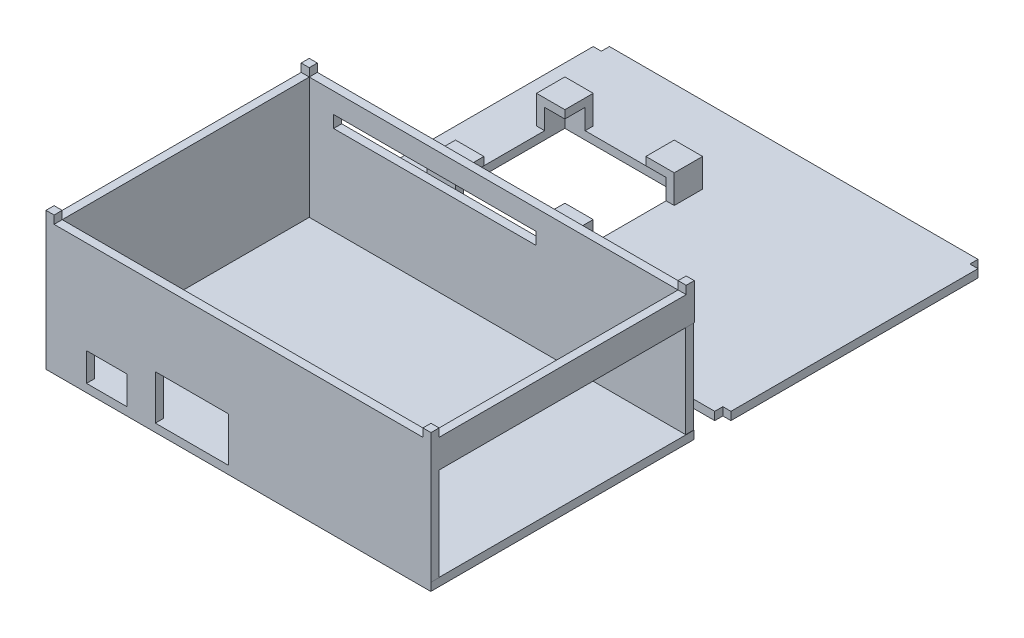
from build123d import *

# Parameters (mm, degrees)
ESQUISSE1_W                = 95
ESQUISSE1_H                = 65
BOSS_EXTRU_1_DEPTH         = 2
ESQUISSE22_W               = 65
ESQUISSE22_H               = 30
BOSS_EXTRU_6_DEPTH         = 2
ESQUISSE23_W               = 93.058073386
ESQUISSE23_H               = 30
BOSS_EXTRU_7_DEPTH         = 2
ESQUISSE26_W               = 92.923280672
ESQUISSE26_H               = 30
BOSS_EXTRU_8_DEPTH         = 2
ESQUISSE27_W               = 10
ESQUISSE27_H               = 7
ENL_V_MAT_EXTRU_4_DEPTH    = 2
ESQUISSE28_W               = 18
ESQUISSE28_H               = 11
ENL_V_MAT_EXTRU_5_DEPTH    = 2
ESQUISSE30_W               = 65
ESQUISSE30_H               = 7
BOSS_EXTRU_9_DEPTH         = 2
ESQUISSE31_W               = 95
ESQUISSE31_H               = 65
BOSS_EXTRU_11_DEPTH        = 2
ESQUISSE32_W               = 2
ESQUISSE32_H               = 2
BOSS_EXTRU_12_DEPTH        = 2
R_P_TITION_LIN_AIRE1_COUNT = 2
R_P_TITION_LIN_AIRE1_PITCH = 63
ESQUISSE33_W               = 2
ESQUISSE33_H               = 2
BOSS_EXTRU_13_DEPTH        = 2
R_P_TITION_LIN_AIRE4_COUNT = 2
R_P_TITION_LIN_AIRE4_PITCH = 63
ESQUISSE34_W               = 2
ESQUISSE34_H               = 2
ENL_V_MAT_EXTRU_6_DEPTH    = 2
R_P_TITION_LIN_AIRE5_COUNT = 2
R_P_TITION_LIN_AIRE5_PITCH = 63
ESQUISSE35_W               = 2
ESQUISSE35_H               = 2
ENL_V_MAT_EXTRU_7_DEPTH    = 2
R_P_TITION_LIN_AIRE7_COUNT = 2
R_P_TITION_LIN_AIRE7_PITCH = 63
ESQUISSE36_W               = 30
ESQUISSE36_H               = 30
ENL_V_MAT_EXTRU_8_DEPTH    = 2
ESQUISSE37_W               = 5
ESQUISSE37_H               = 7
BOSS_EXTRU_14_DEPTH        = 2
ESQUISSE38_W               = 7
ESQUISSE38_H               = 7
BOSS_EXTRU_15_DEPTH        = 2
ESQUISSE39_W               = 5
ESQUISSE39_H               = 5
BOSS_EXTRU_16_DEPTH        = 2
ESQUISSE40_W               = 5
ESQUISSE40_H               = 7
BOSS_EXTRU_17_DEPTH        = 2
ESQUISSE41_W               = 7
ESQUISSE41_H               = 7
BOSS_EXTRU_19_DEPTH        = 2
ESQUISSE43_W               = 5.015402863
ESQUISSE43_H               = 5
BOSS_EXTRU_20_DEPTH        = 2
ESQUISSE44_W               = 5
ESQUISSE44_H               = 7
BOSS_EXTRU_21_DEPTH        = 2
ESQUISSE45_W               = 7
ESQUISSE45_H               = 7
BOSS_EXTRU_22_DEPTH        = 2
ESQUISSE46_W               = 5.00193494
ESQUISSE46_H               = 5
BOSS_EXTRU_23_DEPTH        = 2
ESQUISSE48_W               = 5
ESQUISSE48_H               = 7
BOSS_EXTRU_24_DEPTH        = 2
ESQUISSE49_W               = 7
ESQUISSE49_H               = 7
BOSS_EXTRU_25_DEPTH        = 2
ESQUISSE50_W               = 5
ESQUISSE50_H               = 5
BOSS_EXTRU_26_DEPTH        = 2
ESQUISSE51_W               = 50
ESQUISSE51_H               = 3
ENL_V_MAT_EXTRU_9_DEPTH    = 2


with BuildPart() as part:
    # Esquisse1 → Boss.-Extru.1 (new body)
    with BuildSketch(Plane(origin=(0, 0, 0), x_dir=(1, 0, 0), z_dir=(0, 1, 0))):
        with Locations((-31.555880748, 23.267126069)):
            Rectangle(ESQUISSE1_W, ESQUISSE1_H)
    extrude(amount=BOSS_EXTRU_1_DEPTH)

    # Esquisse22 → Boss.-Extru.6 (add)
    with BuildSketch(Plane.ZY.offset(79.055880748)):
        with Locations((-23.267126069, 17)):
            Rectangle(ESQUISSE22_W, ESQUISSE22_H)
    extrude(amount=-BOSS_EXTRU_6_DEPTH)

    # Esquisse23 → Boss.-Extru.7 (add)
    with BuildSketch(Plane.XY.offset(9.232873931)):
        with Locations((-30.526844055, 17)):
            Rectangle(ESQUISSE23_W, ESQUISSE23_H)
    extrude(amount=-BOSS_EXTRU_7_DEPTH)

    # Esquisse26 → Boss.-Extru.8 (add)
    with BuildSketch(Plane(origin=(0, 0, -55.767126069), x_dir=(-1, 0, 0), z_dir=(0, 0, -1))):
        with Locations((30.594240412, 17)):
            Rectangle(ESQUISSE26_W, ESQUISSE26_H)
    extrude(amount=-BOSS_EXTRU_8_DEPTH)

    # Esquisse27 → Enlèv. mat.-Extru.4 (cut)
    with BuildSketch(Plane.XY.offset(9.232873931)):
        with Locations((-64.055880748, 5.5)):
            Rectangle(ESQUISSE27_W, ESQUISSE27_H)
    extrude(amount=-ENL_V_MAT_EXTRU_4_DEPTH, mode=Mode.SUBTRACT)

    # Esquisse28 → Enlèv. mat.-Extru.5 (cut)
    with BuildSketch(Plane.XY.offset(9.232873931)):
        with Locations((-43.055880748, 7.5)):
            Rectangle(ESQUISSE28_W, ESQUISSE28_H)
    extrude(amount=-ENL_V_MAT_EXTRU_5_DEPTH, mode=Mode.SUBTRACT)

    # Esquisse30 → Boss.-Extru.9 (add)
    with BuildSketch(Plane(origin=(16.002192638, 0, 0), x_dir=(0, 0, -1), z_dir=(1, 0, 0))):
        with Locations((23.267126069, 28.5)):
            Rectangle(ESQUISSE30_W, ESQUISSE30_H)
    extrude(amount=-BOSS_EXTRU_9_DEPTH)

    # Esquisse32 → Boss.-Extru.12 (add)
    with BuildSketch(Plane(origin=(0, 32, 0), x_dir=(1, 0, 0), z_dir=(0, 1, 0))):
        with Locations((-78.055880748, 54.767126069)):
            Rectangle(ESQUISSE32_W, ESQUISSE32_H)
    boss_extru_12 = extrude(amount=BOSS_EXTRU_12_DEPTH)

    # Répétition linéaire1: Boss.-Extru.12 ×2
    with Locations(*[(0, 0, i * R_P_TITION_LIN_AIRE1_PITCH) for i in range(1, R_P_TITION_LIN_AIRE1_COUNT)]):
        add(boss_extru_12)

    # Esquisse33 → Boss.-Extru.13 (add)
    with BuildSketch(Plane(origin=(0, 32, 0), x_dir=(1, 0, 0), z_dir=(0, 1, 0))):
        with Locations((15.002192638, 54.767126069)):
            Rectangle(ESQUISSE33_W, ESQUISSE33_H)
    boss_extru_13 = extrude(amount=BOSS_EXTRU_13_DEPTH)

    # Répétition linéaire4: Boss.-Extru.13 ×2
    with Locations(*[(0, 0, i * R_P_TITION_LIN_AIRE4_PITCH) for i in range(1, R_P_TITION_LIN_AIRE4_COUNT)]):
        add(boss_extru_13)

    # Esquisse51 → Enlèv. mat.-Extru.9 (cut)
    with BuildSketch(Plane(origin=(0, 0, -55.767126069), x_dir=(-1, 0, 0), z_dir=(0, 0, -1))):
        with Locations((46.055880748, 25.5)):
            Rectangle(ESQUISSE51_W, ESQUISSE51_H)
    extrude(amount=-ENL_V_MAT_EXTRU_9_DEPTH, mode=Mode.SUBTRACT)


with BuildPart() as body_2:
    # Esquisse31 → Boss.-Extru.11 (new body)
    with BuildSketch(Plane(origin=(0, 0, 0), x_dir=(1, 0, 0), z_dir=(0, 1, 0))):
        with Locations((-31.027576349, 94.847888589)):
            Rectangle(ESQUISSE31_W, ESQUISSE31_H)
    extrude(amount=BOSS_EXTRU_11_DEPTH)

    # Esquisse34 → Enlèv. mat.-Extru.6 (cut)
    with BuildSketch(Plane(origin=(0, 2, 0), x_dir=(1, 0, 0), z_dir=(0, 1, 0))):
        with Locations((-77.527576349, 126.347888589)):
            Rectangle(ESQUISSE34_W, ESQUISSE34_H)
    enl_v_mat_extru_6 = extrude(amount=-ENL_V_MAT_EXTRU_6_DEPTH, mode=Mode.SUBTRACT)

    # Répétition linéaire5: Enlèv. mat.-Extru.6 ×2
    with Locations(*[(0, 0, i * R_P_TITION_LIN_AIRE5_PITCH) for i in range(1, R_P_TITION_LIN_AIRE5_COUNT)]):
        add(enl_v_mat_extru_6, mode=Mode.SUBTRACT)

    # Esquisse35 → Enlèv. mat.-Extru.7 (cut)
    with BuildSketch(Plane(origin=(0, 2, 0), x_dir=(1, 0, 0), z_dir=(0, 1, 0))):
        with Locations((15.472423651, 126.347888589)):
            Rectangle(ESQUISSE35_W, ESQUISSE35_H)
    enl_v_mat_extru_7 = extrude(amount=-ENL_V_MAT_EXTRU_7_DEPTH, mode=Mode.SUBTRACT)

    # Répétition linéaire7: Enlèv. mat.-Extru.7 ×2
    with Locations(*[(0, 0, i * R_P_TITION_LIN_AIRE7_PITCH) for i in range(1, R_P_TITION_LIN_AIRE7_COUNT)]):
        add(enl_v_mat_extru_7, mode=Mode.SUBTRACT)

    # Esquisse36 → Enlèv. mat.-Extru.8 (cut)
    with BuildSketch(Plane(origin=(0, 2, 0), x_dir=(1, 0, 0), z_dir=(0, 1, 0))):
        with Locations((-51.527576349, 91.347888589)):
            Rectangle(ESQUISSE36_W, ESQUISSE36_H)
    extrude(amount=-ENL_V_MAT_EXTRU_8_DEPTH, mode=Mode.SUBTRACT)

    # Esquisse37 → Boss.-Extru.14 (add)
    with BuildSketch(Plane(origin=(-66.527576349, 0, 0), x_dir=(0, 0, -1), z_dir=(1, 0, 0))):
        with Locations((103.847888589, 5.5)):
            Rectangle(ESQUISSE37_W, ESQUISSE37_H)
    extrude(amount=-BOSS_EXTRU_14_DEPTH)

    # Esquisse38 → Boss.-Extru.15 (add)
    with BuildSketch(Plane(origin=(0, 0, -106.347888589), x_dir=(-1, 0, 0), z_dir=(0, 0, -1))):
        with Locations((65.027576349, 5.5)):
            Rectangle(ESQUISSE38_W, ESQUISSE38_H)
    extrude(amount=BOSS_EXTRU_15_DEPTH)

    # Esquisse39 → Boss.-Extru.16 (add)
    with BuildSketch(Plane(origin=(0, 9, 0), x_dir=(1, 0, 0), z_dir=(0, 1, 0))):
        with Locations((-64.027576349, 103.847888589)):
            Rectangle(ESQUISSE39_W, ESQUISSE39_H)
    extrude(amount=-BOSS_EXTRU_16_DEPTH)

    # Esquisse40 → Boss.-Extru.17 (add)
    with BuildSketch(Plane(origin=(-66.527576349, 0, 0), x_dir=(0, 0, -1), z_dir=(1, 0, 0))):
        with Locations((78.847888589, 5.5)):
            Rectangle(ESQUISSE40_W, ESQUISSE40_H)
    extrude(amount=-BOSS_EXTRU_17_DEPTH)

    # Esquisse41 → Boss.-Extru.19 (add)
    with BuildSketch(Plane.XY.offset(-76.347888589)):
        with Locations((-65.027576349, 5.5)):
            Rectangle(ESQUISSE41_W, ESQUISSE41_H)
    extrude(amount=BOSS_EXTRU_19_DEPTH)

    # Esquisse43 → Boss.-Extru.20 (add)
    with BuildSketch(Plane(origin=(0, 9, 0), x_dir=(1, 0, 0), z_dir=(0, 1, 0))):
        with Locations((-64.019874918, 78.847888589)):
            Rectangle(ESQUISSE43_W, ESQUISSE43_H)
    extrude(amount=-BOSS_EXTRU_20_DEPTH)

    # Esquisse44 → Boss.-Extru.21 (add)
    with BuildSketch(Plane.ZY.offset(36.527576349)):
        with Locations((-103.847888589, 5.5)):
            Rectangle(ESQUISSE44_W, ESQUISSE44_H)
    extrude(amount=-BOSS_EXTRU_21_DEPTH)

    # Esquisse45 → Boss.-Extru.22 (add)
    with BuildSketch(Plane(origin=(0, 0, -106.347888589), x_dir=(-1, 0, 0), z_dir=(0, 0, -1))):
        with Locations((38.027576349, 5.5)):
            Rectangle(ESQUISSE45_W, ESQUISSE45_H)
    extrude(amount=BOSS_EXTRU_22_DEPTH)

    # Esquisse46 → Boss.-Extru.23 (add)
    with BuildSketch(Plane(origin=(0, 9, 0), x_dir=(1, 0, 0), z_dir=(0, 1, 0))):
        with Locations((-39.028543819, 103.847888589)):
            Rectangle(ESQUISSE46_W, ESQUISSE46_H)
    extrude(amount=-BOSS_EXTRU_23_DEPTH)

    # Esquisse48 → Boss.-Extru.24 (add)
    with BuildSketch(Plane(origin=(0, 0, -76.347888589), x_dir=(-1, 0, 0), z_dir=(0, 0, -1))):
        with Locations((39.027576349, 5.5)):
            Rectangle(ESQUISSE48_W, ESQUISSE48_H)
    extrude(amount=-BOSS_EXTRU_24_DEPTH)

    # Esquisse49 → Boss.-Extru.25 (add)
    with BuildSketch(Plane(origin=(-36.527576349, 0, 0), x_dir=(0, 0, -1), z_dir=(1, 0, 0))):
        with Locations((77.847888589, 5.5)):
            Rectangle(ESQUISSE49_W, ESQUISSE49_H)
    extrude(amount=BOSS_EXTRU_25_DEPTH)

    # Esquisse50 → Boss.-Extru.26 (add)
    with BuildSketch(Plane(origin=(0, 9, 0), x_dir=(1, 0, 0), z_dir=(0, 1, 0))):
        with Locations((-39.027576349, 78.847888589)):
            Rectangle(ESQUISSE50_W, ESQUISSE50_H)
    extrude(amount=-BOSS_EXTRU_26_DEPTH)


solid = Compound([part.part, body_2.part])
